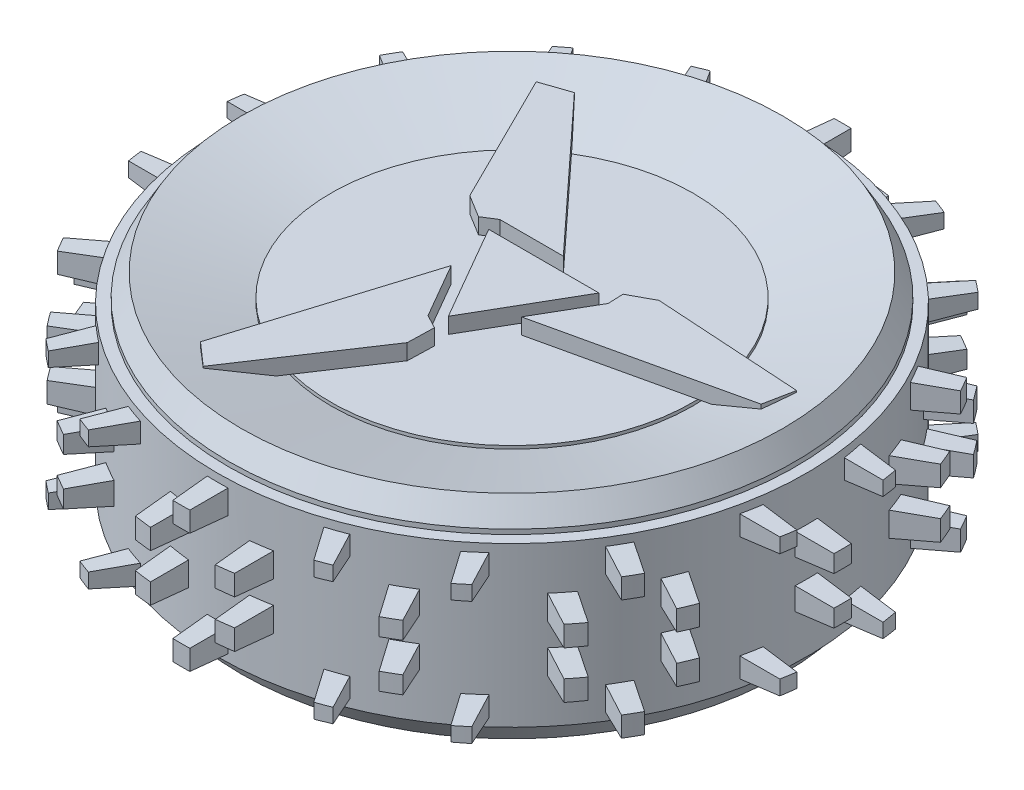
from build123d import *

# Parameters (mm, degrees)
SKETCH_1_R                = 90
EXTRUDE_1_DEPTH           = 33.75
CHAMFER_1_SIZE            = 7
CHAMFER_1_SIZE2           = 4.041451884
CHAMFER_2_SIZE            = 7
CHAMFER_2_SIZE2           = 4.041451884
SKETCH_2_R                = 93.5
EXTRUDE_2_DEPTH           = 25.25
SKETCH_4_W                = 8
SKETCH_4_H                = 9
EXTRUDE_3_DEPTH           = 25.25
EXTRUDE_3_TAPER           = 3
EXTRUDE_3_OTHER_WAY_DEPTH = 25.25
EXTRUDE_3_OTHER_WAY_TAPER = 3
SKETCH_5_W                = 8
SKETCH_5_H                = 7.925773434
SKETCH_5_W_2              = 9
SKETCH_5_H_2              = 9
EXTRUDE_4_DEPTH           = 25.25
EXTRUDE_4_TAPER           = 4
EXTRUDE_4_OTHER_WAY_DEPTH = 25.25
EXTRUDE_4_OTHER_WAY_TAPER = 4
PATTERN_CIRCULAR_1_COUNT  = 6
PATTERN_CIRCULAR_2_COUNT  = 6
SKETCH_6_R                = 115
SKETCH_6_R_2              = 105
CUT_EXTRUDE_1_DEPTH       = 153.624334629
CUT_EXTRUDE_1_DEPTH_BACK  = 153.624334629
EXTRUDE_5_DEPTH           = 5
SKETCH_9_R                = 30
SKETCH_9_R_2              = 24.5
CUT_EXTRUDE_2_DEPTH       = 161.344161169
CUT_EXTRUDE_2_DEPTH_BACK  = 6
SKETCH_10_R               = 24.5
CUT_EXTRUDE_3_DEPTH       = 161.344161169
SKETCH_11_R               = 2
CUT_EXTRUDE_4_DEPTH       = 12
HOLE_WIZARD_M6_1_D        = 5
HOLE_WIZARD_M6_1_DEPTH    = 12
HOLE_WIZARD_M6_1_TIP      = 1.502151548
EXTRUDE_6_DEPTH           = 20
SKETCH_14_R               = 24.5
SKETCH_14_R_2             = 3.1
EXTRUDE_10_DEPTH          = 5
CUT_EXTRUDE_6_DEPTH       = 5
FILLET_1_R                = 2
SKETCH_16_R               = 12
CUT_EXTRUDE_7_DEPTH       = 5


with BuildPart() as part:
    # 草图1 → 凸台-拉伸1 (new, symmetric)
    with BuildSketch(Plane(origin=(0, 0, 0), x_dir=(1, 0, 0), z_dir=(0, 1, 0))):
        with Locations(Location((0, 0, 0), (0, 0, 270))):
            Circle(SKETCH_1_R)
    extrude(amount=EXTRUDE_1_DEPTH, both=True)

    # 倒角1
    chamfer_1_edges = [part.edges().sort_by_distance(p)[0] for p in [
        (0, 33.75, -90),
    ]]
    chamfer_1_side = [part.faces().sort_by_distance(p)[0] for p in [
        (0, 0, -90),
    ]]
    chamfer(chamfer_1_edges, length=CHAMFER_1_SIZE, length2=CHAMFER_1_SIZE2, reference=chamfer_1_side[0])

    # 倒角2
    chamfer_2_edges = [part.edges().sort_by_distance(p)[0] for p in [
        (0, -33.75, -90),
    ]]
    chamfer_2_side = [part.faces().sort_by_distance(p)[0] for p in [
        (0, -3.5, -90),
    ]]
    chamfer(chamfer_2_edges, length=CHAMFER_2_SIZE, length2=CHAMFER_2_SIZE2, reference=chamfer_2_side[0])

    # 草图2 → 凸台-拉伸2 (add, symmetric)
    with BuildSketch(Plane(origin=(0, 0, 0), x_dir=(1, 0, 0), z_dir=(0, 1, 0))):
        with Locations(Location((0, 0, 0), (0, 0, 270))):
            Circle(SKETCH_2_R)
    extrude(amount=EXTRUDE_2_DEPTH, both=True)

    # 草图4 → 凸台-拉伸3 (add)
    with BuildSketch(Plane.XY.offset(80)):
        with Locations((0, 19)):
            Rectangle(SKETCH_4_W, SKETCH_4_H)
        with Locations((-13, 7.5)):
            Rectangle(SKETCH_4_W, SKETCH_4_H)
        with Locations((13, 7.5)):
            Rectangle(SKETCH_4_W, SKETCH_4_H)
        with Locations((13, -7.5)):
            Rectangle(SKETCH_4_W, SKETCH_4_H)
        with Locations((-13, -7.5)):
            Rectangle(SKETCH_4_W, SKETCH_4_H)
        with Locations((0, -19)):
            Rectangle(SKETCH_4_W, SKETCH_4_H)
    extrude_3 = extrude(amount=EXTRUDE_3_DEPTH, taper=EXTRUDE_3_TAPER)

    # 草图4 → 凸台-拉伸3 other way (add)
    with BuildSketch(Plane.XY.offset(80)):
        with Locations((0, 19)):
            Rectangle(SKETCH_4_W, SKETCH_4_H)
        with Locations((-13, 7.5)):
            Rectangle(SKETCH_4_W, SKETCH_4_H)
        with Locations((13, 7.5)):
            Rectangle(SKETCH_4_W, SKETCH_4_H)
        with Locations((13, -7.5)):
            Rectangle(SKETCH_4_W, SKETCH_4_H)
        with Locations((-13, -7.5)):
            Rectangle(SKETCH_4_W, SKETCH_4_H)
        with Locations((0, -19)):
            Rectangle(SKETCH_4_W, SKETCH_4_H)
    extrude(amount=-EXTRUDE_3_OTHER_WAY_DEPTH, taper=EXTRUDE_3_OTHER_WAY_TAPER)

    # 草图5 → 凸台-拉伸4 (add)
    with BuildSketch(Plane(origin=(80, 0, 0), x_dir=(0, 0, -1), z_dir=(1, 0, 0))):
        with Locations((-16, 19.537113283)):
            Rectangle(SKETCH_5_W, SKETCH_5_H)
        with Locations((0, 7.5)):
            Rectangle(SKETCH_5_W_2, SKETCH_5_H_2)
        with Locations((16, 19.537113283)):
            Rectangle(SKETCH_5_W, SKETCH_5_H)
        with Locations((16, -19.537113283)):
            Rectangle(SKETCH_5_W, SKETCH_5_H)
        with Locations((0, -7.5)):
            Rectangle(SKETCH_5_W_2, SKETCH_5_H_2)
        with Locations((-16, -19.537113283)):
            Rectangle(SKETCH_5_W, SKETCH_5_H)
    extrude_4 = extrude(amount=EXTRUDE_4_DEPTH, taper=EXTRUDE_4_TAPER)

    # 草图5 → 凸台-拉伸4 other way (add)
    with BuildSketch(Plane(origin=(80, 0, 0), x_dir=(0, 0, -1), z_dir=(1, 0, 0))):
        with Locations((-16, 19.537113283)):
            Rectangle(SKETCH_5_W, SKETCH_5_H)
        with Locations((0, 7.5)):
            Rectangle(SKETCH_5_W_2, SKETCH_5_H_2)
        with Locations((16, 19.537113283)):
            Rectangle(SKETCH_5_W, SKETCH_5_H)
        with Locations((16, -19.537113283)):
            Rectangle(SKETCH_5_W, SKETCH_5_H)
        with Locations((0, -7.5)):
            Rectangle(SKETCH_5_W_2, SKETCH_5_H_2)
        with Locations((-16, -19.537113283)):
            Rectangle(SKETCH_5_W, SKETCH_5_H)
    extrude(amount=-EXTRUDE_4_OTHER_WAY_DEPTH, taper=EXTRUDE_4_OTHER_WAY_TAPER)

    # 阵列(圆周)1: 凸台-拉伸4 ×6 about axis
    pattern_circular_1_axis = Axis((0, 0, 0), (0, 1, 0))
    for i in range(1, PATTERN_CIRCULAR_1_COUNT):
        add(extrude_4.rotate(pattern_circular_1_axis, i * 360 / PATTERN_CIRCULAR_1_COUNT))

    # 阵列(圆周)2: 凸台-拉伸3 ×6 about axis
    pattern_circular_2_axis = Axis((0, 0, 0), (0, 1, 0))
    for i in range(1, PATTERN_CIRCULAR_2_COUNT):
        add(extrude_3.rotate(pattern_circular_2_axis, i * 360 / PATTERN_CIRCULAR_2_COUNT))

    # 草图6 → 切除-拉伸1 (cut, two sides)
    with BuildSketch(Plane(origin=(0, 0, 0), x_dir=(1, 0, 0), z_dir=(0, 1, 0))) as cut_extrude_1_sk:
        Circle(SKETCH_6_R)
        Circle(SKETCH_6_R_2, mode=Mode.SUBTRACT)
    extrude(amount=CUT_EXTRUDE_1_DEPTH, mode=Mode.SUBTRACT)
    extrude(cut_extrude_1_sk.sketch, amount=-CUT_EXTRUDE_1_DEPTH_BACK, mode=Mode.SUBTRACT)

    # 草图7 → 切除-旋转1 (revolve, cut)
    with BuildSketch(Plane.XY, mode=Mode.PRIVATE) as cut_revolve_1_sk:
        Polygon((-85.958548116, 33.75), (-57.5, 25.75), (-57.5, 26.75), (0, 26.75), (0, 33.75), align=None)
    cut_revolve_1 = revolve(cut_revolve_1_sk.sketch.rotate(Axis((0, 26.75, 0), (0, 1, 0)), 270), axis=Axis((0, 26.75, 0), (0, 1, 0)), mode=Mode.SUBTRACT)

    # 草图8 → 凸台-拉伸5 (add)
    with BuildSketch(Plane(origin=(0, 26.75, 0), x_dir=(1, 0, 0), z_dir=(0, 1, 0))):
        Polygon((-17.5, 10.103629711), (17.5, 10.103629711), (0, -20.207259422), align=None)
        Polygon((-18.438681103, 14.579903289), (1.715038359, 14.579903289), (-41.480247409, 61.286454156), (-50.538326277, 58.218395184), (-29.778060047, 16.375420053), (-22.595992994, 11.955686482), align=None)
        Polygon((21.65192471, 13.590860716), (21.845907185, 8.678414603), (11.769047454, -8.775218432), (73.815749912, 5.279720934), (75.687772336, 14.658276829), (29.070559787, 17.60084645), align=None)
        Polygon((0.944068284, -25.546547197), (-3.407226082, -23.258317893), (-13.484085813, -5.804684857), (-32.335502502, -66.56617509), (-25.149446059, -72.876672013), (0.70750026, -33.976266503), align=None)
    extrude_5 = extrude(amount=EXTRUDE_5_DEPTH)

    # 镜向1: 切除-旋转1, 凸台-拉伸5 across plane
    add(cut_revolve_1.mirror(Plane.ZX), mode=Mode.SUBTRACT)
    add(extrude_5.mirror(Plane.ZX))

    # 草图9 → 切除-拉伸2 (cut, two sides)
    with BuildSketch(Plane.XZ.offset(26.75)) as cut_extrude_2_sk:
        with Locations(Location((0, 0, 0), (0, 0, 88.434861671))):
            Circle(SKETCH_9_R)
        with Locations(Location((0, 0, 0), (0, 0, 92.555483688))):
            Circle(SKETCH_9_R_2, mode=Mode.SUBTRACT)
    extrude(amount=CUT_EXTRUDE_2_DEPTH, mode=Mode.SUBTRACT)
    extrude(cut_extrude_2_sk.sketch, amount=-CUT_EXTRUDE_2_DEPTH_BACK, mode=Mode.SUBTRACT)

    # 草图10 → 切除-拉伸3 (cut, through all)
    with BuildSketch(Plane.XZ.offset(26.75)):
        with Locations(Location((0, 0, 0), (0, 0, 90))):
            Circle(SKETCH_10_R)
    extrude(amount=CUT_EXTRUDE_3_DEPTH, mode=Mode.SUBTRACT)

    # 草图11 → 切除-拉伸4 (cut)
    with BuildSketch(Plane.XZ.offset(26.75)):
        with Locations(Location((0, 20, 0), (0, 0, 270))):
            Circle(SKETCH_11_R)
        with Locations(Location((17.320508076, 10, 0), (0, 0, 270))):
            Circle(SKETCH_11_R)
        with Locations(Location((17.320508076, -10, 0), (0, 0, 270))):
            Circle(SKETCH_11_R)
        with Locations(Location((0, -20, 0), (0, 0, 270))):
            Circle(SKETCH_11_R)
        with Locations(Location((-17.320508076, -10, 0), (0, 0, 270))):
            Circle(SKETCH_11_R)
        with Locations(Location((-17.320508076, 10, 0), (0, 0, 270))):
            Circle(SKETCH_11_R)
    extrude(amount=-CUT_EXTRUDE_4_DEPTH, mode=Mode.SUBTRACT)

    # M6 螺纹孔1
    with Locations(Plane(origin=(0, -26.75, 20), x_dir=(0, 0, -1), z_dir=(0, -1, 0))):
        with Locations((0, 0), (10, -17.320508076), (30, -17.320508076), (40, 0), (30, 17.320508076), (10, 17.320508076)):
            Hole(HOLE_WIZARD_M6_1_D / 2, depth=HOLE_WIZARD_M6_1_DEPTH)
            with Locations((0, 0, -(HOLE_WIZARD_M6_1_DEPTH + HOLE_WIZARD_M6_1_TIP / 2))):  # 118° drill point
                Cone(0, HOLE_WIZARD_M6_1_D / 2, HOLE_WIZARD_M6_1_TIP, mode=Mode.SUBTRACT)

    # 草图13 → 凸台-拉伸6 (add)
    with BuildSketch(Plane.XZ.offset(26.75)):
        with BuildLine():
            ThreePointArc((-7.810865227, 21.633085411), (-11.631430688, 19.84212237), (-15.060523329, 17.383343667))
            ThreePointArc((-15.060523329, 17.383343667), (-15.363499895, 13.151534929), (-11.131691156, 12.848558363))
            ThreePointArc((-11.131691156, 12.848558363), (-8.597144421, 14.665916535), (-5.773248211, 15.989671826))
            ThreePointArc((-5.773248211, 15.989671826), (-3.970349926, 19.830187126), (-7.810865227, 21.633085411))
        make_face()
    extrude(amount=EXTRUDE_6_DEPTH)


with BuildPart() as body_2:
    # 草图14 → 凸台-拉伸10 (new body)
    with BuildSketch(Plane.XZ.offset(26.75)):
        with Locations(Location((0, 0, 0), (0, 0, 270))):
            Circle(SKETCH_14_R)
        with Locations(Location((-17.320508076, 10, 0), (0, 0, 270))):
            Circle(SKETCH_14_R_2, mode=Mode.SUBTRACT)
        with Locations(Location((0, 20, 0), (0, 0, 270))):
            Circle(SKETCH_14_R_2, mode=Mode.SUBTRACT)
        with Locations(Location((17.320508076, 10, 0), (0, 0, 270))):
            Circle(SKETCH_14_R_2, mode=Mode.SUBTRACT)
        with Locations(Location((17.320508076, -10, 0), (0, 0, 270))):
            Circle(SKETCH_14_R_2, mode=Mode.SUBTRACT)
        with Locations(Location((0, -20, 0), (0, 0, 270))):
            Circle(SKETCH_14_R_2, mode=Mode.SUBTRACT)
        with Locations(Location((-17.320508076, -10, 0), (0, 0, 270))):
            Circle(SKETCH_14_R_2, mode=Mode.SUBTRACT)
    extrude(amount=EXTRUDE_10_DEPTH)

    # 草图15 → 切除-拉伸6 (cut)
    with BuildSketch(Plane.XZ.offset(31.75)):
        Polygon((-18.083828674, 17.798458936), (-6.696175835, 24.473888722), (-2.448175062, 17.227200552), (-13.835827901, 10.551770766), align=None)
    extrude(amount=-CUT_EXTRUDE_6_DEPTH, mode=Mode.SUBTRACT)

    # 圆角1
    fillet_1_edges = [body_2.edges().sort_by_distance(p)[0] for p in [
        (-6.238139687, -29.25, 23.692522307),
        (-17.625792525, -29.25, 17.017092521),
        (-13.835827901, -29.25, 10.551770766),
        (-2.448175062, -29.25, 17.227200552),
    ]]
    fillet(fillet_1_edges, radius=FILLET_1_R)

    # 草图16 → 切除-拉伸7 (cut)
    with BuildSketch(Plane.XZ.offset(31.75)):
        with Locations(Location((0, 0, 0), (0, 0, 270))):
            Circle(SKETCH_16_R)
    extrude(amount=-CUT_EXTRUDE_7_DEPTH, mode=Mode.SUBTRACT)


with BuildPart() as body_3:
    # 镜向2: mirrored copy
    add(body_2.part.mirror(Plane(origin=(0, -31.75, 0), x_dir=(0, 0, 1), z_dir=(0, -1, 0))))


with BuildPart() as body_4:
    # 镜向3: mirrored copy
    add(body_3.part.mirror(Plane.ZX.offset(-36.75)))


solid = Compound([part.part, body_2.part, body_3.part, body_4.part])
